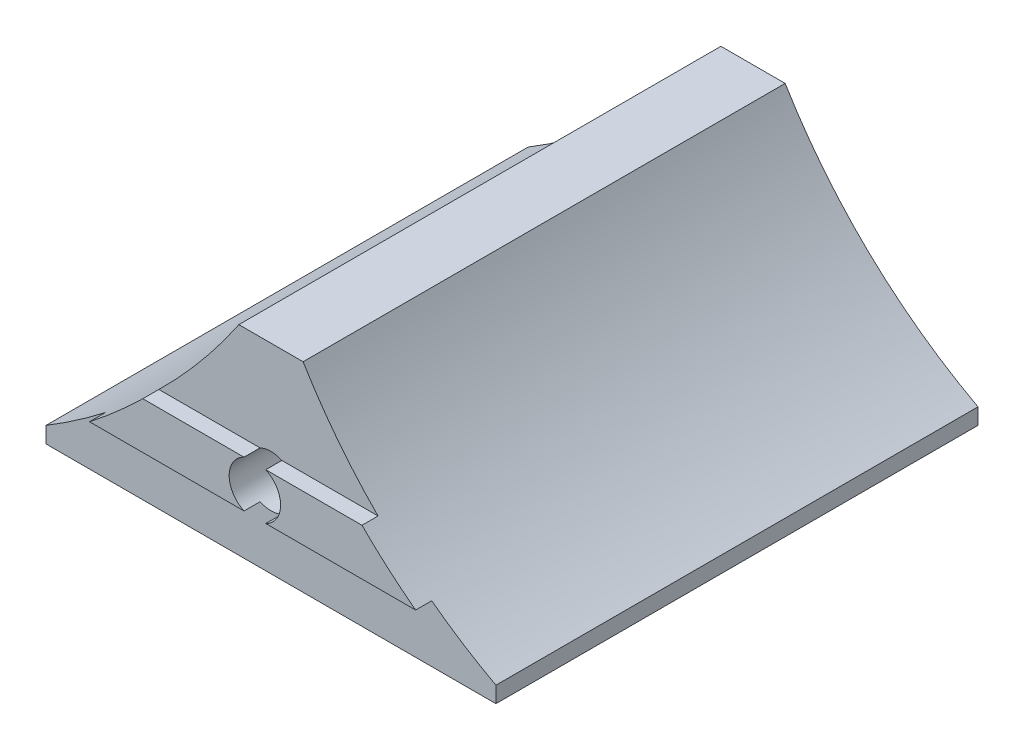
from build123d import *

# Parameters (mm, degrees)
MAIN_DEPTH        = 30
FIX_2_DEPTH       = 1
SKETCH4_R         = 1.6
FIXHOLE_DEPTH     = 32
SKETCH6_R         = 4.25
FIXTOOLHOLE_DEPTH = 10


with BuildPart() as part:
    # Sketch1 → Main (new body)
    with BuildSketch(Plane.XY):
        with BuildLine():
            Line((4.012678164, 8.096844755), (4.012678164, 9.096844755))
            ThreePointArc((4.012678164, 9.096844755), (10.635131042, 14.159397508), (16.012678164, 20.528723174))
            Line((16.012678164, 20.528723174), (20.012678164, 20.528723174))
            ThreePointArc((20.012678164, 20.528723174), (25.237773803, 13.999369756), (32.012678164, 9.096844755))
            Line((32.012678164, 9.096844755), (32.012678164, 8.096844755))
            Line((32.012678164, 8.096844755), (4.012678164, 8.096844755))
        make_face()
    extrude(amount=MAIN_DEPTH)

    # Sketch5 → Fix 2 (add)
    with BuildSketch(Plane.XY.offset(30)):
        with BuildLine():
            Line((11.035981199, 14.546844755), (24.677385704, 14.546844755))
            ThreePointArc((24.677385704, 14.546844755), (26.295048181, 13.037479939), (28.015846782, 11.646844755))
            Line((28.015846782, 11.646844755), (7.71870745, 11.646844755))
            ThreePointArc((7.71870745, 11.646844755), (9.418864977, 13.0493498), (11.035981199, 14.546844755))
        make_face()
    extrude(amount=FIX_2_DEPTH)

    # Sketch4 → FixHole (cut, through all)
    with BuildSketch(Plane.XY.offset(31)):
        with Locations((18.012678164, 13.096844755)):
            Circle(SKETCH4_R)
    extrude(amount=-FIXHOLE_DEPTH, mode=Mode.SUBTRACT)

    # Sketch6 → FixToolHole (cut)
    with BuildSketch(Plane(origin=(0, 0, 0), x_dir=(-1, 0, 0), z_dir=(0, 0, -1))):
        with Locations((-18.012678164, 13.096844755)):
            Circle(SKETCH6_R)
    extrude(amount=-FIXTOOLHOLE_DEPTH, mode=Mode.SUBTRACT)


solid = part.part
